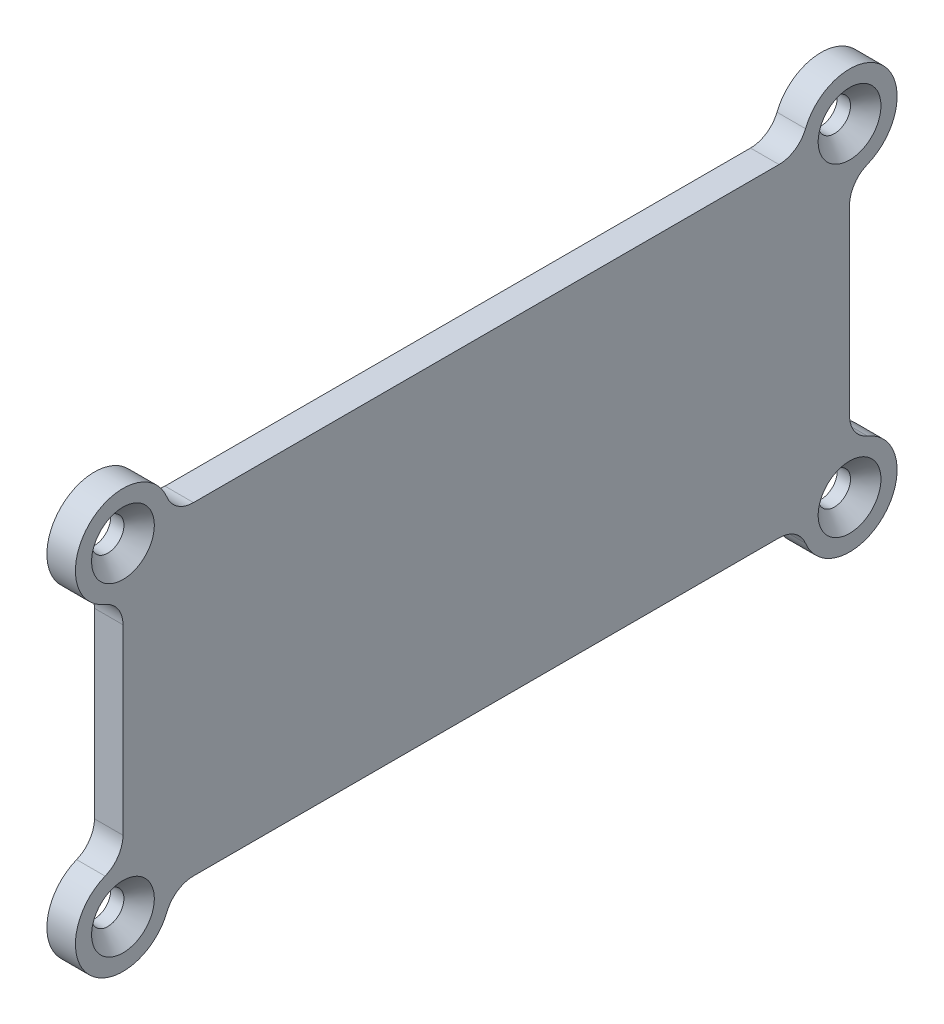
from build123d import *

# Parameters (mm, degrees)
EXTRUDE_1_DEPTH          = 3
FILLET_1_R               = 3
HOLE_WIZARD_1_AT_2_COUNT = 2
HOLE_WIZARD_1_AT_2_PITCH = 34
HOLE_WIZARD_1_AT_3_COUNT = 2
HOLE_WIZARD_1_AT_3_PITCH = 83.623920023
HOLE_WIZARD_1_AT_4_COUNT = 2
HOLE_WIZARD_1_AT_4_PITCH = 76.4


with BuildPart() as part:
    # 草图1 → 凸台-拉伸1 (new body)
    with BuildSketch(Plane(origin=(0, 0, 0), x_dir=(0, 0, -1), z_dir=(1, 0, 0))):
        with BuildLine():
            Line((-38.2, 12), (-38.2, -12))
            ThreePointArc((-38.2, -12), (-41.735533906, -20.535533906), (-33.2, -17))
            Line((-33.2, -17), (33.2, -17))
            ThreePointArc((33.2, -17), (41.735533906, -20.535533906), (38.2, -12))
            Line((38.2, -12), (38.2, 12))
            ThreePointArc((38.2, 12), (41.735533906, 20.535533906), (33.2, 17))
            Line((33.2, 17), (-33.2, 17))
            ThreePointArc((-33.2, 17), (-41.735533906, 20.535533906), (-38.2, 12))
        make_face()
    extrude(amount=EXTRUDE_1_DEPTH)

    # 圆角1
    fillet_1_edges = [part.edges().sort_by_distance(p)[0] for p in [
        (1.5, 17, 33.2),
        (1.5, 17, -33.2),
        (1.5, 12, -38.2),
        (1.5, -12, -38.2),
        (1.5, -17, -33.2),
        (1.5, -17, 33.2),
        (1.5, -12, 38.2),
        (1.5, 12, 38.2),
    ]]
    fillet(fillet_1_edges, radius=FILLET_1_R)

    # 草图2 → 打孔尺寸(%根据十字)槽半沉头木螺钉的类型1 (revolve, cut)
    with BuildSketch(Plane(origin=(3, 17, 38.2), x_dir=(0, 0, -1), z_dir=(0, 1, 0))):
        Polygon((0, 0), (0, 3), (1.7, 3), (1.7, 1.6), (3.3, 0), align=None)
    hole_wizard_1 = revolve(axis=Axis((9.35, 17, 38.2), (-1, 0, 0)), mode=Mode.SUBTRACT)

    # 打孔尺寸(%根据十字)槽半沉头木螺钉的类型1 at 2: 打孔尺寸(%根据十字)槽半沉头木螺钉的类型1 ×2
    with Locations(*[(0, -i * HOLE_WIZARD_1_AT_2_PITCH, 0) for i in range(1, HOLE_WIZARD_1_AT_2_COUNT)]):
        add(hole_wizard_1, mode=Mode.SUBTRACT)

    # 打孔尺寸(%根据十字)槽半沉头木螺钉的类型1 at 3: 打孔尺寸(%根据十字)槽半沉头木螺钉的类型1 ×2
    with Locations(*[Vector(0, -0.406582231, -0.913614191) * (i * HOLE_WIZARD_1_AT_3_PITCH) for i in range(1, HOLE_WIZARD_1_AT_3_COUNT)]):
        add(hole_wizard_1, mode=Mode.SUBTRACT)

    # 打孔尺寸(%根据十字)槽半沉头木螺钉的类型1 at 4: 打孔尺寸(%根据十字)槽半沉头木螺钉的类型1 ×2
    with Locations(*[(0, 0, -i * HOLE_WIZARD_1_AT_4_PITCH) for i in range(1, HOLE_WIZARD_1_AT_4_COUNT)]):
        add(hole_wizard_1, mode=Mode.SUBTRACT)


solid = part.part
